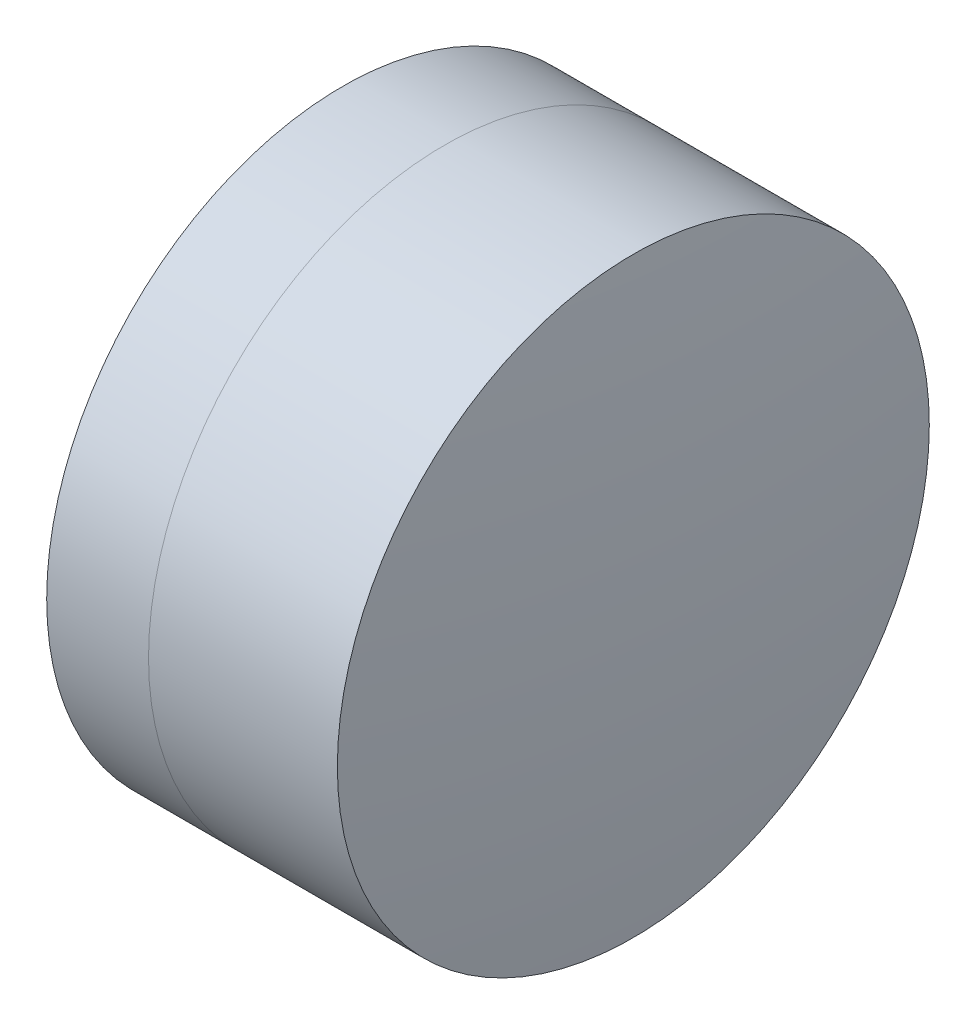
from build123d import *


with BuildPart() as part:
    # 草图1 one side → 旋转1 (revolve)
    with BuildSketch(Plane(origin=(0, 0, 0), x_dir=(1, 0, 0), z_dir=(0, 1, 0)), mode=Mode.PRIVATE) as revolve_1_sk:
        with BuildLine():
            ThreePointArc((260.588255373, 3.175), (260.133963869, 1.616302341), (259.980712755, 0))
            Line((259.980712755, 0), (262.480712755, 0))
            ThreePointArc((262.480712755, 0), (262.277621447, 1.637124747), (261.680659788, 3.175))
            Line((261.680659788, 3.175), (260.588255373, 3.175))
        make_face()
    revolve(revolve_1_sk.sketch.rotate(Axis((124.523309526, 0, 0), (1, 0, 0)), 180), axis=Axis((124.523309526, 0, 0), (1, 0, 0)))  # turned: the seam where the file's is


with BuildPart() as body_2:
    # 草图2 one side → 旋转3 (revolve)
    with BuildSketch(Plane(origin=(0, 0, 0), x_dir=(1, 0, 0), z_dir=(0, 1, 0)), mode=Mode.PRIVATE) as revolve_3_sk:
        with BuildLine():
            Line((263.706384906, 3.175), (261.680659788, 3.175))
            ThreePointArc((261.680659788, 3.175), (262.277621447, 1.637124747), (262.480712755, 0))
            Line((262.480712755, 0), (263.880712755, 0))
            ThreePointArc((263.880712755, 0), (263.837097995, 1.589891128), (263.706384906, 3.175))
        make_face()
    revolve(revolve_3_sk.sketch.rotate(Axis((-0.551919993, 0, 0), (1, 0, 0)), 180), axis=Axis((-0.551919993, 0, 0), (1, 0, 0)))  # turned: the seam where the file's is


solid = Compound([part.part, body_2.part])
